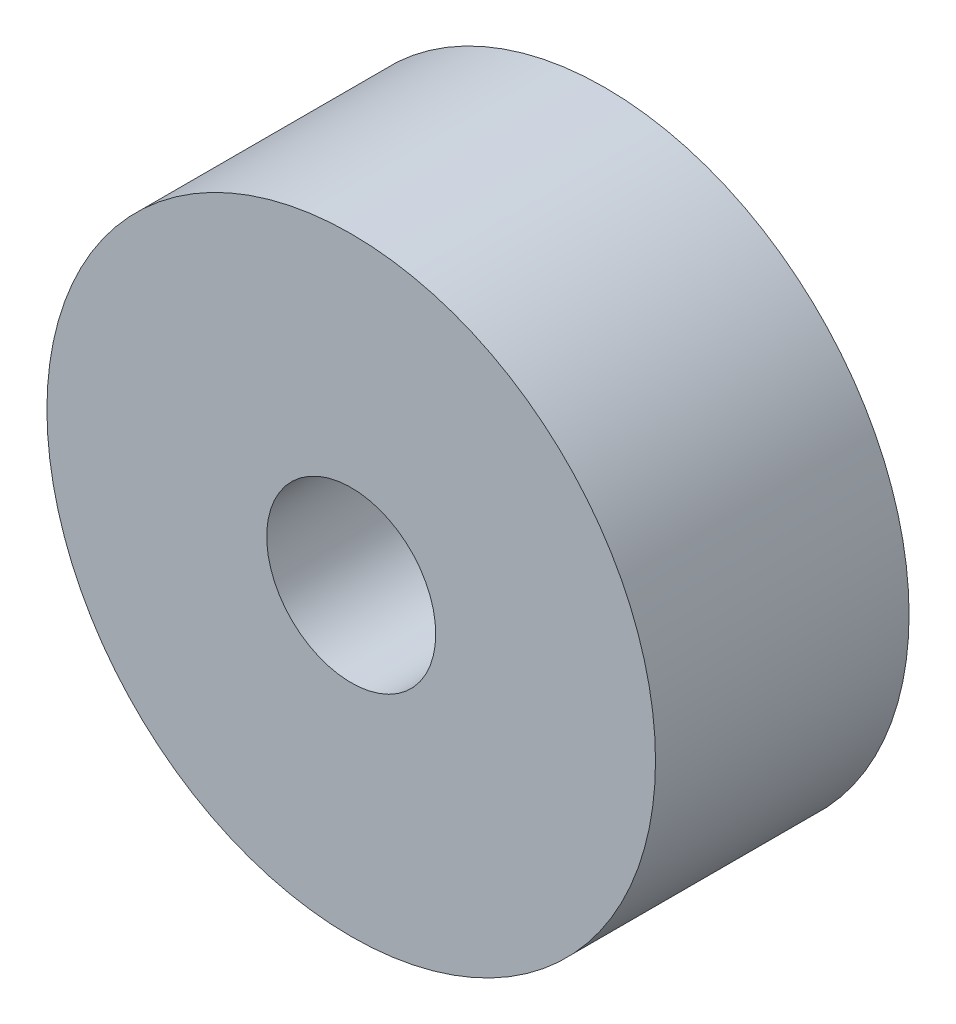
from build123d import *

# Parameters (mm, degrees)
SKETCH1_R           = 3.6
SKETCH1_R_2         = 1
BOSS_EXTRUDE1_DEPTH = 3


with BuildPart() as part:
    # Sketch1 → Boss-Extrude1 (new body)
    with BuildSketch(Plane.XY):
        Circle(SKETCH1_R)
        Circle(SKETCH1_R_2, mode=Mode.SUBTRACT)
    extrude(amount=BOSS_EXTRUDE1_DEPTH)


solid = part.part
